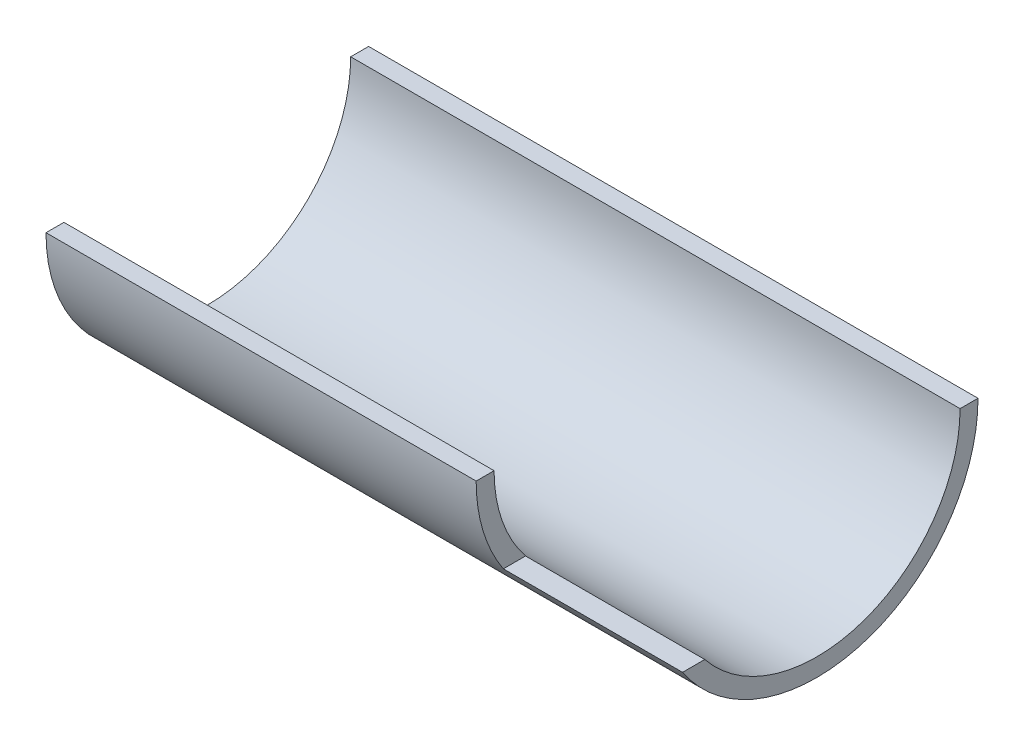
from build123d import *

# Parameters (mm, degrees)
BOSS_EXTRUDE1_DEPTH = 107.95
SKETCH2_W           = 31.75
SKETCH2_H           = 15.875
CUT_EXTRUDE1_DEPTH  = 127
SKETCH3_OUTSIDE_W   = 91.34
SKETCH3_OUTSIDE_H   = 59.59
SKETCH3_OUTSIDE_R   = 28.575
CUT_EXTRUDE2_DEPTH  = 108.95


with BuildPart() as part:
    # Sketch1 → Boss-Extrude1 (new body)
    with BuildSketch(Plane(origin=(0, 0, 0), x_dir=(0, 0, -1), z_dir=(1, 0, 0))):
        with BuildLine():
            Line((-25.4, 0), (-31.75, 0))
            ThreePointArc((-31.75, 0), (0, -31.75), (31.75, 0))
            Line((31.75, 0), (25.4, 0))
            ThreePointArc((25.4, 0), (0, -25.4), (-25.4, 0))
        make_face()
    extrude(amount=-BOSS_EXTRUDE1_DEPTH)

    # Sketch2 → Cut-Extrude1 (cut)
    with BuildSketch(Plane.XY):
        with Locations((-15.875, -7.9375)):
            Rectangle(SKETCH2_W, SKETCH2_H)
    extrude(amount=CUT_EXTRUDE1_DEPTH, mode=Mode.SUBTRACT)

    # Sketch3 outside → Cut-Extrude2 (cut, through all)
    with BuildSketch(Plane(origin=(0, 0, 0), x_dir=(0, 0, -1), z_dir=(1, 0, 0))):
        with Locations((0, -15.875)):
            Rectangle(SKETCH3_OUTSIDE_W, SKETCH3_OUTSIDE_H)
        Circle(SKETCH3_OUTSIDE_R, mode=Mode.SUBTRACT)
    extrude(amount=-CUT_EXTRUDE2_DEPTH, mode=Mode.SUBTRACT)


solid = part.part
